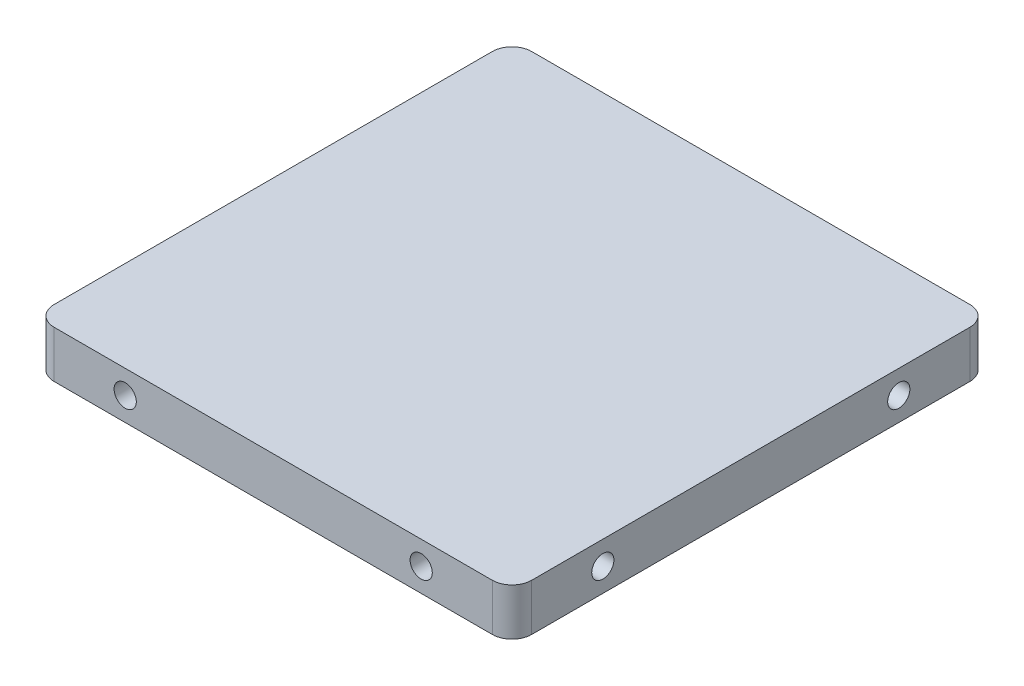
from build123d import *

# Parameters (mm, degrees)
SKETCH1_W            = 96.825
SKETCH1_H            = 96.825
BOSS_EXTRUDE1_DEPTH  = 4.7625
FILLET1_R            = 4
M4_CLEARANCE_HOLE1_D = 4.5
M4_CLEARANCE_HOLE2_D = 4.5


with BuildPart() as part:
    # Sketch1 → Boss-Extrude1 (new body, symmetric)
    with BuildSketch(Plane(origin=(0, 0, 0), x_dir=(1, 0, 0), z_dir=(0, 1, 0))):
        Rectangle(SKETCH1_W, SKETCH1_H)
    extrude(amount=BOSS_EXTRUDE1_DEPTH, both=True)

    # Fillet1
    fillet1_edges = [part.edges().sort_by_distance(p)[0] for p in [
        (-48.4125, 0, -48.4125),
        (48.4125, 0, -48.4125),
        (48.4125, 0, 48.4125),
        (-48.4125, 0, 48.4125),
    ]]
    fillet(fillet1_edges, radius=FILLET1_R)

    # M4 Clearance Hole1 (through all)
    with Locations(Plane.ZY.offset(48.4125)):
        with Locations((-30, 0), (30, 0)):
            Hole(M4_CLEARANCE_HOLE1_D / 2)

    # M4 Clearance Hole2 (through all)
    with Locations(Plane(origin=(0, 0, -48.4125), x_dir=(-1, 0, 0), z_dir=(0, 0, -1))):
        with Locations((-30, 0), (30, 0)):
            Hole(M4_CLEARANCE_HOLE2_D / 2)


solid = part.part
